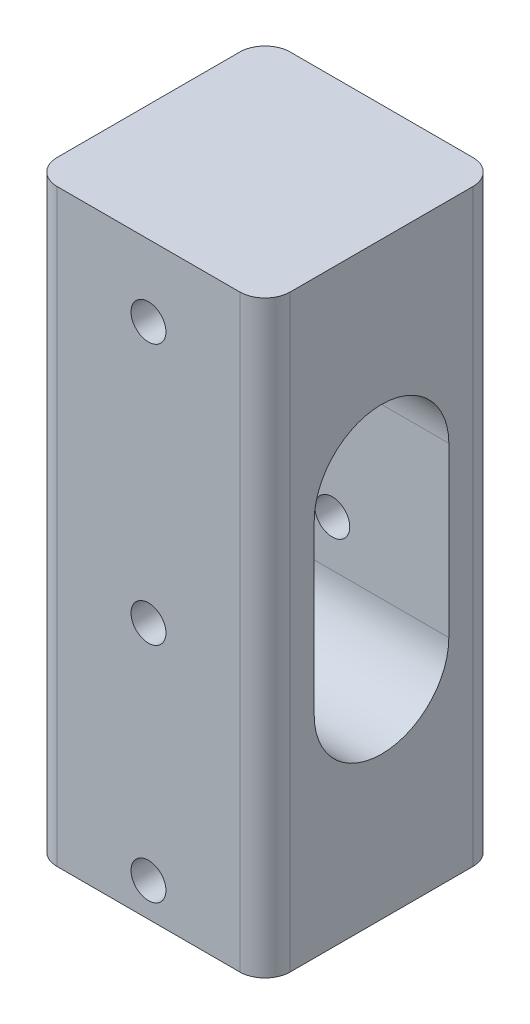
from build123d import *

# Parameters (mm, degrees)
SKETCH_1_W          = 27.7
SKETCH_1_H          = 27.7
EXTRUDE_1_DEPTH     = 70
SKETCH_2_R          = 2.075
CUT_EXTRUDE_1_DEPTH = 70
CUT_EXTRUDE_2_DEPTH = 70
FILLET_1_R          = 3


with BuildPart() as part:
    # 草图1 → 凸台-拉伸1 (new body)
    with BuildSketch(Plane(origin=(0, 0, 0), x_dir=(1, 0, 0), z_dir=(0, 1, 0))):
        Rectangle(SKETCH_1_W, SKETCH_1_H)
    extrude(amount=EXTRUDE_1_DEPTH)

    # 草图2 → 切除-拉伸1 (cut)
    with BuildSketch(Plane.XY.offset(13.85)):
        with Locations((0, 4)):
            Circle(SKETCH_2_R)
        with Locations((0, 30.5)):
            Circle(SKETCH_2_R)
        with Locations((0, 61.5)):
            Circle(SKETCH_2_R)
    extrude(amount=-CUT_EXTRUDE_1_DEPTH, mode=Mode.SUBTRACT)

    # 草图3 → 切除-拉伸2 (cut)
    with BuildSketch(Plane.ZY.offset(13.85)):
        with BuildLine():
            Line((-8, 25), (-8, 45))
            ThreePointArc((-8, 45), (0, 53), (8, 45))
            Line((8, 45), (8, 25))
            ThreePointArc((8, 25), (0, 17), (-8, 25))
        make_face()
    extrude(amount=-CUT_EXTRUDE_2_DEPTH, mode=Mode.SUBTRACT)

    # 圆角1
    fillet_1_edges = [part.edges().sort_by_distance(p)[0] for p in [
        (13.85, 35, 13.85),
        (-13.85, 35, 13.85),
        (-13.85, 35, -13.85),
        (13.85, 35, -13.85),
    ]]
    fillet(fillet_1_edges, radius=FILLET_1_R)


solid = part.part
